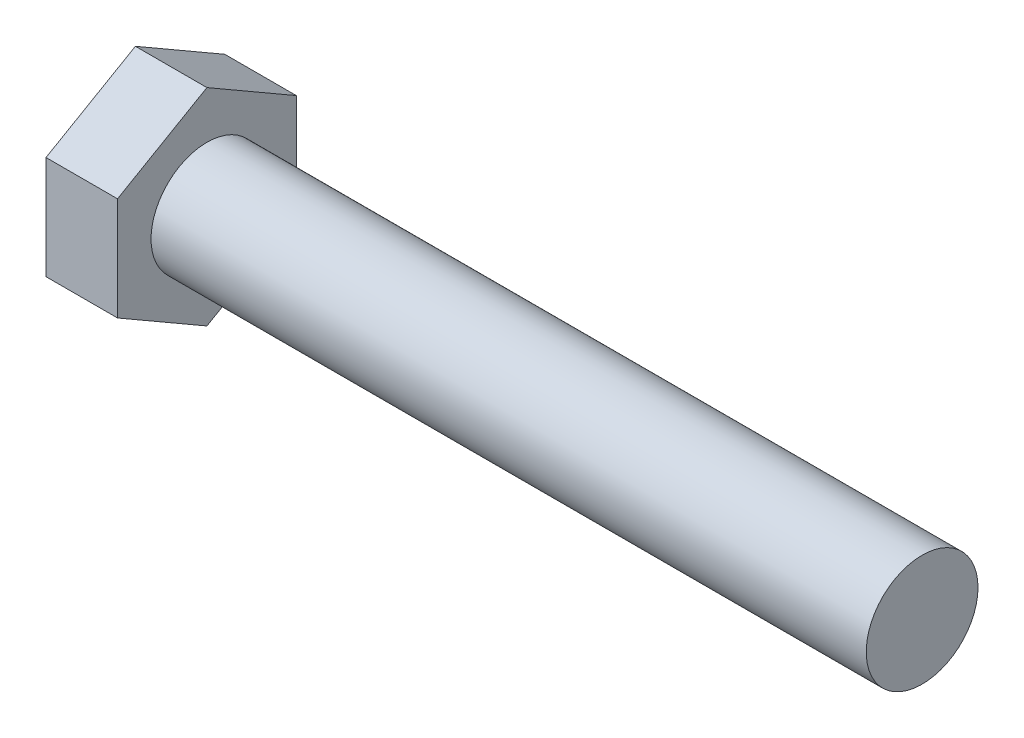
from build123d import *

# Parameters (mm, degrees)
BOSS_EXTRUDE1_DEPTH = 5.08
SKETCH2_R           = 3.96875
BOSS_EXTRUDE2_DEPTH = 50.8


with BuildPart() as part:
    # Sketch1 → Boss-Extrude1 (new body)
    with BuildSketch(Plane(origin=(0, 0, 0), x_dir=(0, 0, -1), z_dir=(1, 0, 0))):
        Polygon((6.35, 3.666174209), (0, 7.332348419), (-6.35, 3.666174209), (-6.35, -3.666174209), (0, -7.332348419), (6.35, -3.666174209), align=None)
    extrude(amount=BOSS_EXTRUDE1_DEPTH)

    # Sketch2 → Boss-Extrude2 (add)
    with BuildSketch(Plane(origin=(5.08, 0, 0), x_dir=(0, 0, -1), z_dir=(1, 0, 0))):
        Circle(SKETCH2_R)
    extrude(amount=BOSS_EXTRUDE2_DEPTH)


solid = part.part
